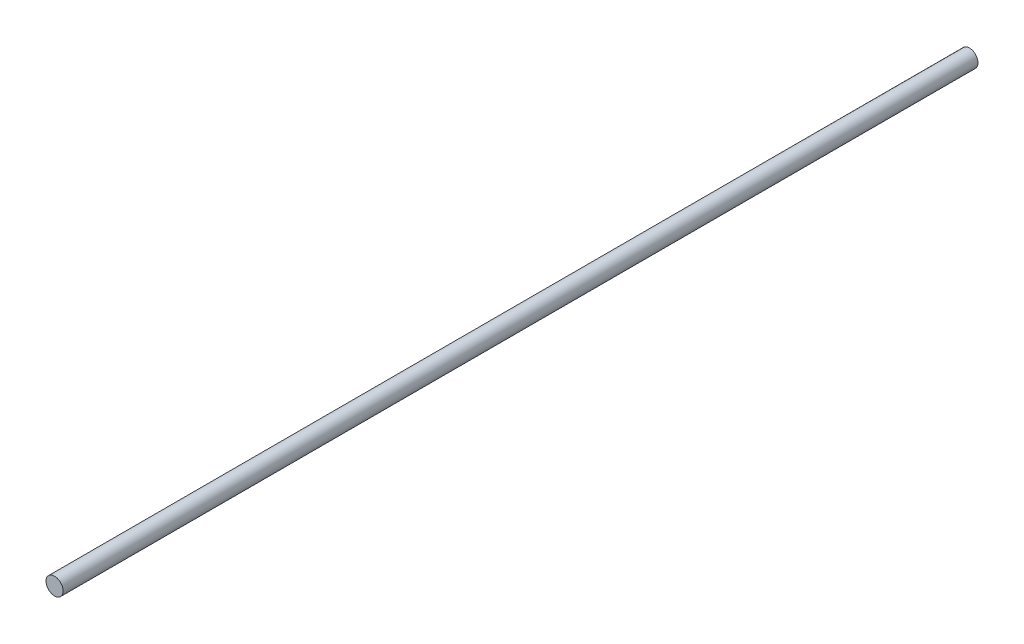
from build123d import *

# Parameters (mm, degrees)
ESBO_O1_R                = 1.5
RESSALTO_EXTRUS_O1_DEPTH = 160


with BuildPart() as part:
    # Esboço1 → Ressalto-extrusão1 (new body)
    with BuildSketch(Plane.XY):
        Circle(ESBO_O1_R)
    extrude(amount=RESSALTO_EXTRUS_O1_DEPTH)


solid = part.part
